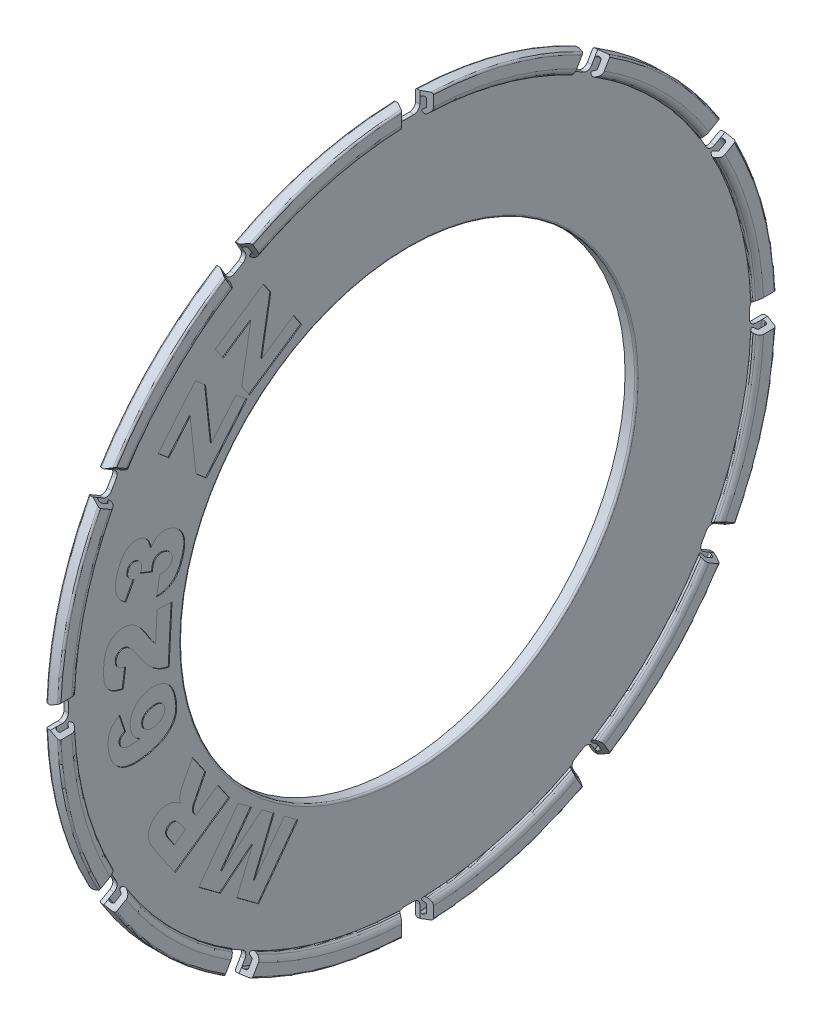
from build123d import *
from OCP.BRepFilletAPI import BRepFilletAPI_MakeFillet

# Parameters (mm, degrees)
FILLET1_R1         = 0.02
FILLET1_R2         = 0.08
SKETCH3_W          = 0.249361734
SKETCH3_H          = 0.345695775
CUT_EXTRUDE2_DEPTH = 6.799732894
CUT_EXTRUDE2_TAPER = -30
CUT_EXTRUDE3_REACH = 7.8
CIRPATTERN2_COUNT  = 12
CUT_EXTRUDE1_DEPTH = 0.01


with BuildPart() as part:
    # Sketch1 → Revolve1 (revolve)
    with BuildSketch(Plane.XY):
        Polygon((1.02, -2.65), (1.1, -2.65), (1.1, -4.1), (1.248703916, -4.1), (1.248703916, -3.92), (1.187420361, -3.868576991), (1.15528098, -3.906879213), (1.198703916, -3.943315383), (1.198703916, -4.05), (1.15, -4.05), (1.15, -2.6), (1.02, -2.6), align=None)
    revolve(axis=Axis((-6.429017492, 0, 0), (1, 0, 0)))

    # Fillet1: one fillet with a radius per group of edges: ONE call of the kernel's fillet builder (fillet() takes one radius for all edges)
    fillet1_edges_1 = [part.edges().sort_by_distance(p)[0] for p in [
        (1.187420361, 3.868576991, 0),
        (1.15528098, 3.906879213, 0),
        (1.15, 2.6, 0),
        (1.248703916, 4.1, 0),
        (1.1, 4.1, 0),
        (1.15, 4.05, 0),
        (1.198703916, 4.05, 0),
    ]]
    fillet1_edges_2 = [part.edges().sort_by_distance(p)[0] for p in [
        (1.248703916, 3.92, 0),
    ]]
    fillet1 = BRepFilletAPI_MakeFillet(part.part.solid().wrapped)
    for e in fillet1_edges_1:
        fillet1.Add(FILLET1_R1, e.wrapped)
    for e in fillet1_edges_2:
        fillet1.Add(FILLET1_R2, e.wrapped)
    add(Compound.cast(fillet1.Shape()), mode=Mode.REPLACE)

    # Sketch3 → Cut-Extrude2 (cut, through all)
    with BuildSketch(Plane(origin=(1.15, 0, 0), x_dir=(0, 0, -1), z_dir=(1, 0, 0))):
        with Locations((0, 3.957248854)):
            Rectangle(SKETCH3_W, SKETCH3_H)
    cut_extrude2 = extrude(amount=CUT_EXTRUDE2_DEPTH, taper=CUT_EXTRUDE2_TAPER, mode=Mode.SUBTRACT)

    # Cut-Extrude3: up to this face of the body (flat: up to its plane)
    cut_extrude3_end = Plane(part.part.faces().sort_by_distance((1.1, 3.964600173, 0))[0])
    # Sketch4 → Cut-Extrude3 (cut, up to the picked face)
    with BuildSketch(Plane(origin=(1.15, 0, 0), x_dir=(0, 0, -1), z_dir=(1, 0, 0)), mode=Mode.PRIVATE) as cut_extrude3_sk1:
        with BuildLine():
            Line((-0.124680867, 4.098103791), (-0.124680867, 3.96268108))
            ThreePointArc((-0.124680867, 3.96268108), (-0.104178342, 3.913183605), (-0.054680867, 3.89268108))
            Line((-0.054680867, 3.89268108), (0.054680867, 3.89268108))
            ThreePointArc((0.054680867, 3.89268108), (0.104178342, 3.913183605), (0.124680867, 3.96268108))
            Line((0.124680867, 3.96268108), (0.124680867, 4.098103791))
            ThreePointArc((0.124680867, 4.098103791), (0, 4.1), (-0.124680867, 4.098103791))
        make_face()
    cut_extrude3_tool1 = split(extrude(cut_extrude3_sk1.sketch, amount=-CUT_EXTRUDE3_REACH, mode=Mode.PRIVATE), bisect_by=cut_extrude3_end, keep=Keep.BOTH, mode=Mode.PRIVATE)
    cut_extrude3 = cut_extrude3_tool1.solids().sort_by(Axis((1.15, 3.999757, 0), (-1, 0, 0)))[0]
    add(cut_extrude3, mode=Mode.SUBTRACT)

    # CirPattern2: Cut-Extrude2, Cut-Extrude3 ×12 about axis
    cirpattern2_axis = Axis((0, 0, 0), (1, 0, 0))
    add([cut_extrude2.rotate(cirpattern2_axis, i * 360 / CIRPATTERN2_COUNT) for i in range(1, CIRPATTERN2_COUNT)], mode=Mode.SUBTRACT)
    add([cut_extrude3.rotate(cirpattern2_axis, i * 360 / CIRPATTERN2_COUNT) for i in range(1, CIRPATTERN2_COUNT)], mode=Mode.SUBTRACT)

    # Sketch2 → Cut-Extrude1 (cut)
    with BuildSketch(Plane(origin=(1.15, 0, 0), x_dir=(0, 0, -1), z_dir=(1, 0, 0))):
        Polygon((-2.212074833, 2.706157821), (-1.663424265, 3.076135499), (-1.57895795, 2.950729655), (-1.682904784, 2.346376977), (-1.31825381, 2.592318535), (-1.22739545, 2.457476814), (-1.822768826, 2.055995483), (-1.910583356, 2.186119266), (-1.807701862, 2.784079899), (-2.121825239, 2.572229249), align=None)
        Polygon((-2.866893351, 1.999189565), (-2.440756987, 2.505226496), (-2.325091403, 2.407823899), (-2.259649033, 1.798144516), (-1.976420542, 2.13448786), (-1.852080039, 2.029780068), (-2.314590185, 1.480672925), (-2.434669325, 1.581880311), (-2.499502929, 2.185015457), (-2.743465997, 1.89524273), align=None)
        with BuildLine():
            Line((-3.141397188, 0.890050122), (-3.234994996, 0.712290381))
            add(Edge.make_bspline(
                [(-3.234994996, 0.712290381), (-3.241652025, 0.716717018), (-3.254716815, 0.72540454), (-3.272940512, 0.739733467), (-3.289267173, 0.755137837), (-3.30379652, 0.771514362), (-3.316687436, 0.788790714), (-3.327785169, 0.807039293), (-3.337140333, 0.826251788), (-3.344830176, 0.846382003), (-3.35047259, 0.867753095), (-3.354119764, 0.890280058), (-3.355562981, 0.914076921), (-3.355057782, 0.939058583), (-3.352589821, 0.965358989), (-3.347977427, 0.992862404), (-3.341211907, 1.021605488), (-3.335394145, 1.040951868), (-3.332397593, 1.050916599)],
                knots=[0, 0, 0, 0, 0.996965878, 1.956601256, 2.88770829, 3.793173997, 4.684173077, 5.573012264, 6.45318163, 7.346402628, 8.25663212, 9.205419306, 10.188307953, 11.226283579, 12.319409183, 13.480414381, 14.702238262, 16, 16, 16, 16], degree=3))
            add(Edge.make_bspline(
                [(-3.332397593, 1.050916599), (-3.328675336, 1.062176722), (-3.321480778, 1.083940828), (-3.308895369, 1.114677512), (-3.295848569, 1.142701673), (-3.281461002, 1.167473761), (-3.266605518, 1.189563268), (-3.250552217, 1.208460808), (-3.233834011, 1.224700397), (-3.215990926, 1.237706128), (-3.197629089, 1.247986463), (-3.179187478, 1.256354815), (-3.160432751, 1.262318172), (-3.141460028, 1.266199054), (-3.122239136, 1.267729801), (-3.102852561, 1.266870021), (-3.083215593, 1.264078942), (-3.070339067, 1.26038676), (-3.063779493, 1.258505885)],
                knots=[0, 0, 0, 0, 1.486482005, 2.873143656, 4.16197067, 5.358788456, 6.461443456, 7.494932611, 8.462177862, 9.376883809, 10.254180828, 11.09697377, 11.911647764, 12.716227884, 13.52017922, 14.322241245, 15.145314161, 16, 16, 16, 16], degree=3))
            add(Edge.make_bspline(
                [(-3.063779493, 1.258505885), (-3.05627325, 1.255786904), (-3.041489309, 1.25043173), (-3.021159139, 1.238562115), (-3.002838189, 1.224060775), (-2.986931475, 1.206418047), (-2.973065732, 1.186063316), (-2.961590577, 1.162779945), (-2.952222287, 1.136674978), (-2.948014303, 1.118088437), (-2.945831035, 1.108445008)],
                knots=[0, 0, 0, 0, 0.951343852, 1.873721842, 2.795821485, 3.730286132, 4.69776014, 5.726874251, 6.820612936, 8, 8, 8, 8], degree=3))
            add(Edge.make_bspline(
                [(-2.945831035, 1.108445008), (-2.942066207, 1.114493909), (-2.934964492, 1.125904141), (-2.923542305, 1.141107076), (-2.912985264, 1.154144046), (-2.905277386, 1.161181261), (-2.901695483, 1.164451501)],
                knots=[0, 0, 0, 0, 1.193944278, 2.252174855, 3.187773934, 4, 4, 4, 4], degree=3))
            add(Edge.make_bspline(
                [(-2.901695483, 1.164451501), (-2.896016699, 1.168960545), (-2.884778888, 1.177883543), (-2.866219024, 1.188611368), (-2.846507989, 1.196530549), (-2.825832536, 1.202100475), (-2.8040212, 1.204879141), (-2.781249093, 1.204467835), (-2.757514572, 1.201111708), (-2.741798329, 1.196608404), (-2.733676003, 1.194281047)],
                knots=[0, 0, 0, 0, 0.972616807, 1.924722696, 2.865728001, 3.81734653, 4.792250057, 5.807182763, 6.866728094, 8, 8, 8, 8], degree=3))
            add(Edge.make_bspline(
                [(-2.733676003, 1.194281047), (-2.723405031, 1.19061102), (-2.702896462, 1.183282892), (-2.67424629, 1.167070072), (-2.647600099, 1.147128777), (-2.627326004, 1.127542297), (-2.612408075, 1.110339787), (-2.602292888, 1.09653717), (-2.593376442, 1.082090984), (-2.585363251, 1.067079644), (-2.578510688, 1.05141923), (-2.5728841, 1.035013445), (-2.568324391, 1.018036173), (-2.564945276, 1.00038764), (-2.562846997, 0.981975525), (-2.561862729, 0.962701691), (-2.562622397, 0.942521542), (-2.564420967, 0.921431427), (-2.567641424, 0.899431172), (-2.572266756, 0.876535574), (-2.578184953, 0.85276001), (-2.583083654, 0.83676179), (-2.585593616, 0.828564732)],
                knots=[0, 0, 0, 0, 1.468544657, 2.93231749, 4.418159492, 5.947000875, 6.72313198, 7.486618499, 8.251635851, 9.01057301, 9.779495404, 10.553996804, 11.347185151, 12.148152775, 12.974626404, 13.8443874, 14.747798274, 15.695402368, 16.697679072, 17.744132734, 18.844154151, 20, 20, 20, 20], degree=3))
            add(Edge.make_bspline(
                [(-2.585593616, 0.828564732), (-2.588176667, 0.820631812), (-2.593204973, 0.80518916), (-2.601455124, 0.782965659), (-2.609890597, 0.762261113), (-2.618852313, 0.743130154), (-2.627789962, 0.725318468), (-2.637477837, 0.709217365), (-2.647160583, 0.694500321), (-2.660472911, 0.677170892), (-2.678401335, 0.658069034), (-2.701752935, 0.638203945), (-2.727186872, 0.621922415), (-2.75449044, 0.608912505), (-2.783826529, 0.59908208), (-2.815273453, 0.592770731), (-2.848777556, 0.588711328), (-2.871853383, 0.588811461), (-2.883736879, 0.588863027)],
                knots=[0, 0, 0, 0, 0.957077744, 1.863099244, 2.719135602, 3.521173556, 4.286468441, 5.004158756, 5.675688924, 6.306645927, 7.509093788, 8.673877084, 9.815319901, 10.963391327, 12.135813007, 13.354935907, 14.637855525, 16, 16, 16, 16], degree=3))
            Line((-2.883736879, 0.588863027), (-2.846906522, 0.796604505))
            add(Edge.make_bspline(
                [(-2.846906522, 0.796604505), (-2.84173485, 0.796116766), (-2.831758425, 0.795175892), (-2.817291302, 0.794318742), (-2.803867737, 0.794469213), (-2.791479013, 0.795426964), (-2.780043887, 0.79680153), (-2.769659634, 0.799272541), (-2.760296903, 0.802418464), (-2.749308866, 0.807738941), (-2.737185159, 0.816209466), (-2.724837753, 0.828957383), (-2.715099371, 0.844505375), (-2.71079128, 0.856169694), (-2.708564395, 0.862199066)],
                knots=[0, 0, 0, 0, 1.106073005, 2.133672459, 3.084299769, 3.961649642, 4.778960599, 5.53354789, 6.230416036, 6.877808649, 8.127330516, 9.357275926, 10.633956453, 12, 12, 12, 12], degree=3))
            add(Edge.make_bspline(
                [(-2.708564395, 0.862199066), (-2.706839977, 0.868747377), (-2.703468701, 0.881549469), (-2.70363803, 0.901346703), (-2.707818281, 0.920554317), (-2.716324791, 0.938806489), (-2.72853607, 0.955642955), (-2.74453588, 0.970206792), (-2.764255971, 0.981837995), (-2.778977061, 0.987232435), (-2.786638665, 0.990039975)],
                knots=[0, 0, 0, 0, 0.965377401, 1.887334252, 2.801512917, 3.75979478, 4.747193907, 5.759497664, 6.833928598, 8, 8, 8, 8], degree=3))
            add(Edge.make_bspline(
                [(-2.786638665, 0.990039975), (-2.790731478, 0.99126852), (-2.798646977, 0.993644524), (-2.81050287, 0.996108477), (-2.821908646, 0.997515346), (-2.832910506, 0.997786997), (-2.843467131, 0.997249201), (-2.853574645, 0.995564832), (-2.863234135, 0.992825446), (-2.875300833, 0.98775514), (-2.889215679, 0.97924007), (-2.903214877, 0.965236291), (-2.914556792, 0.947872788), (-2.91941207, 0.934562951), (-2.92193696, 0.927641437)],
                knots=[0, 0, 0, 0, 0.910977311, 1.761829841, 2.57907118, 3.358334845, 4.106094558, 4.829993581, 5.53886079, 6.242091453, 7.617117862, 8.986514487, 10.432897026, 12, 12, 12, 12], degree=3))
            add(Edge.make_bspline(
                [(-2.92193696, 0.927641437), (-2.923067095, 0.923293036), (-2.925529919, 0.913816872), (-2.928047247, 0.897987823), (-2.929577634, 0.879472098), (-2.930153434, 0.866209351), (-2.930459688, 0.859155235)],
                knots=[0, 0, 0, 0, 0.778957448, 1.697527352, 2.775373591, 4, 4, 4, 4], degree=3))
            Line((-2.930459688, 0.859155235), (-3.069867155, 0.914857346))
            add(Edge.make_bspline(
                [(-3.069867155, 0.914857346), (-3.067588218, 0.919585481), (-3.063613972, 0.927830894), (-3.060529501, 0.936446116), (-3.059213746, 0.940121144)],
                knots=[0, 0, 0, 0, 1.146852366, 2, 2, 2, 2], degree=3))
            add(Edge.make_bspline(
                [(-3.059213746, 0.940121144), (-3.057488932, 0.946467761), (-3.054121916, 0.958857017), (-3.053433036, 0.977878384), (-3.056333937, 0.99625753), (-3.062971575, 1.013482869), (-3.072239925, 1.029050803), (-3.08396119, 1.042183531), (-3.098169841, 1.052296388), (-3.1089674, 1.056324962), (-3.114459282, 1.058373985)],
                knots=[0, 0, 0, 0, 1.08461134, 2.117274327, 3.119891392, 4.141971817, 5.150467332, 6.100726669, 7.033986697, 8, 8, 8, 8], degree=3))
            add(Edge.make_bspline(
                [(-3.114459282, 1.058373985), (-3.119745281, 1.059848661), (-3.12988587, 1.06267766), (-3.145293758, 1.063477981), (-3.15978419, 1.061121702), (-3.173328131, 1.056004686), (-3.185295152, 1.047702639), (-3.195766217, 1.037026145), (-3.204053729, 1.023444716), (-3.207782149, 1.013201222), (-3.209731197, 1.007846388)],
                knots=[0, 0, 0, 0, 1.078489428, 2.068959391, 3.010225977, 3.952870467, 4.89514418, 5.856145084, 6.879289992, 8, 8, 8, 8], degree=3))
            add(Edge.make_bspline(
                [(-3.209731197, 1.007846388), (-3.211275304, 1.002153641), (-3.214259155, 0.991152905), (-3.214935751, 0.974388971), (-3.212741472, 0.958363596), (-3.206938511, 0.943012855), (-3.197096815, 0.928370056), (-3.182518323, 0.914860399), (-3.163823026, 0.90155429), (-3.149224101, 0.894065228), (-3.141397188, 0.890050122)],
                knots=[0, 0, 0, 0, 0.931616347, 1.800267452, 2.6365463, 3.478172771, 4.376201162, 5.404643436, 6.608553058, 8, 8, 8, 8], degree=3))
        make_face()
        with BuildLine():
            Line((-2.708015014, 0.451318248), (-2.74088839, -0.176471931))
            add(Edge.make_bspline(
                [(-2.74088839, -0.176471931), (-2.748572037, -0.175055613), (-2.763846211, -0.172240142), (-2.786375266, -0.166130244), (-2.808523188, -0.15893608), (-2.830235826, -0.150141865), (-2.851536635, -0.140191181), (-2.872283803, -0.128566516), (-2.892882866, -0.116095913), (-2.913092173, -0.10166559), (-2.933515243, -0.085095951), (-2.954474013, -0.065749172), (-2.976067704, -0.043250745), (-2.998412162, -0.017730441), (-3.021653279, 0.010661705), (-3.045565624, 0.042201611), (-3.070380175, 0.076643351), (-3.086643344, 0.101021529), (-3.095038147, 0.113605179)],
                knots=[0, 0, 0, 0, 0.793429032, 1.577242224, 2.369314293, 3.15790796, 3.95559384, 4.756022087, 5.572759965, 6.400737883, 7.276468852, 8.243030276, 9.296379999, 10.442997531, 11.68822691, 13.023092273, 14.463364906, 16, 16, 16, 16], degree=3))
            add(Edge.make_bspline(
                [(-3.095038147, 0.113605179), (-3.100138657, 0.121230345), (-3.109918298, 0.135850721), (-3.124342923, 0.156616675), (-3.138057591, 0.175103412), (-3.150645785, 0.191620908), (-3.162362744, 0.205941848), (-3.173127556, 0.218225002), (-3.183131792, 0.228248471), (-3.194859699, 0.238647252), (-3.208873113, 0.248750628), (-3.225586738, 0.257920208), (-3.242111011, 0.264091761), (-3.253272602, 0.265345549), (-3.258644072, 0.265948929)],
                knots=[0, 0, 0, 0, 1.430961346, 2.74370368, 3.943369243, 5.021209643, 5.98274246, 6.829149717, 7.567744642, 8.190069628, 9.272779028, 10.253558271, 11.159531995, 12, 12, 12, 12], degree=3))
            add(Edge.make_bspline(
                [(-3.258644072, 0.265948929), (-3.264197304, 0.265929377), (-3.275157005, 0.265890789), (-3.291099353, 0.261751401), (-3.305941623, 0.254424623), (-3.319135992, 0.243863735), (-3.330639044, 0.231090828), (-3.33910425, 0.215945862), (-3.344759222, 0.199047624), (-3.345980891, 0.18705654), (-3.346610793, 0.180873848)],
                knots=[0, 0, 0, 0, 0.975318568, 1.924860908, 2.872255198, 3.871807218, 4.885053729, 5.881764118, 6.907821917, 8, 8, 8, 8], degree=3))
            add(Edge.make_bspline(
                [(-3.346610793, 0.180873848), (-3.346651482, 0.174464181), (-3.346730155, 0.162070797), (-3.34282415, 0.144119191), (-3.335551895, 0.127959501), (-3.326976319, 0.115863971), (-3.318215593, 0.107344633), (-3.310348999, 0.101321201), (-3.301169733, 0.095810297), (-3.290912101, 0.090672455), (-3.279341455, 0.086084569), (-3.266537306, 0.082085076), (-3.252568629, 0.078173887), (-3.242730943, 0.076248805), (-3.237641637, 0.075252907)],
                knots=[0, 0, 0, 0, 1.361875955, 2.633249472, 3.87602828, 5.114291299, 5.763646398, 6.472382254, 7.219047427, 8.040367039, 8.913013902, 9.866199743, 10.896126464, 12, 12, 12, 12], degree=3))
            Line((-3.237641637, 0.075252907), (-3.265644884, -0.13340172))
            add(Edge.make_bspline(
                [(-3.265644884, -0.13340172), (-3.272761562, -0.131943187), (-3.286653459, -0.129096103), (-3.306689343, -0.123883056), (-3.325544571, -0.118258288), (-3.343151843, -0.112089854), (-3.35950984, -0.1052148), (-3.374629411, -0.097781806), (-3.388474798, -0.089690244), (-3.4053537, -0.078422311), (-3.424141717, -0.062030692), (-3.443778963, -0.039309812), (-3.459799071, -0.01305803), (-3.470985488, 0.010922544), (-3.477903156, 0.0320308), (-3.482573966, 0.04942467), (-3.485872104, 0.068288875), (-3.488755355, 0.088473711), (-3.490253942, 0.110085069), (-3.49121661, 0.133074658), (-3.491207599, 0.15744693), (-3.490494069, 0.174128546), (-3.490127433, 0.182700147)],
                knots=[0, 0, 0, 0, 0.997034666, 1.946231286, 2.840666683, 3.697414948, 4.505731738, 5.274948675, 6.008278083, 6.705507205, 8.058273482, 9.416316791, 10.811400837, 12.266591674, 13.037320093, 13.858197364, 14.736410977, 15.664112006, 16.655904539, 17.708236726, 18.822411473, 20, 20, 20, 20], degree=3))
            add(Edge.make_bspline(
                [(-3.490127433, 0.182700147), (-3.489587271, 0.191634285), (-3.488536162, 0.209019392), (-3.485866374, 0.23428408), (-3.482791294, 0.258015602), (-3.478771372, 0.280134581), (-3.474308868, 0.300687916), (-3.468982828, 0.319649175), (-3.462891862, 0.337017432), (-3.456178095, 0.353001779), (-3.44867817, 0.367772681), (-3.440228115, 0.381488589), (-3.431139547, 0.394449935), (-3.421216585, 0.406506289), (-3.410539876, 0.417656813), (-3.39903043, 0.427921986), (-3.386729999, 0.43735181), (-3.373620496, 0.445837936), (-3.360033876, 0.453451962), (-3.345954173, 0.459833456), (-3.33157377, 0.465207971), (-3.316877888, 0.469472842), (-3.301804303, 0.472509664), (-3.286450319, 0.474517147), (-3.270721879, 0.475274092), (-3.260165565, 0.474929576), (-3.254839283, 0.474755748)],
                knots=[0, 0, 0, 0, 1.517404861, 2.952746514, 4.306707147, 5.573838247, 6.763387418, 7.871665646, 8.910864369, 9.882203375, 10.809307837, 11.716567676, 12.611511199, 13.49148966, 14.36144762, 15.226501486, 16.103911768, 16.986660499, 17.872254385, 18.74216982, 19.604954155, 20.473379898, 21.333716735, 22.209650071, 23.096663112, 24, 24, 24, 24], degree=3))
            add(Edge.make_bspline(
                [(-3.254839283, 0.474755748), (-3.249148243, 0.474333172), (-3.237765937, 0.473488004), (-3.22092676, 0.470706339), (-3.204284641, 0.466720062), (-3.187952833, 0.461419874), (-3.171859955, 0.45478861), (-3.156034606, 0.447035674), (-3.140444687, 0.43803086), (-3.125067638, 0.427572143), (-3.109728457, 0.415341768), (-3.094009646, 0.401385698), (-3.078267179, 0.385117547), (-3.062061896, 0.367028492), (-3.045840551, 0.346621978), (-3.029070468, 0.324326427), (-3.012238998, 0.299772165), (-3.001191797, 0.282567432), (-2.995504868, 0.273710699)],
                knots=[0, 0, 0, 0, 0.800215034, 1.600461711, 2.390998423, 3.198929055, 4.006389423, 4.830702468, 5.669268767, 6.529861257, 7.436785155, 8.419605114, 9.476394529, 10.610505815, 11.825276582, 13.131860768, 14.523525948, 16, 16, 16, 16], degree=3))
            add(Edge.make_bspline(
                [(-2.995504868, 0.273710699), (-2.992266052, 0.268480482), (-2.986063045, 0.258463527), (-2.977022282, 0.244145385), (-2.96891367, 0.231088582), (-2.961358433, 0.219482801), (-2.954718393, 0.209147871), (-2.948783889, 0.200166918), (-2.943618491, 0.192550142), (-2.937597291, 0.183989034), (-2.929755044, 0.173856028), (-2.919602367, 0.161275923), (-2.90813421, 0.147721291), (-2.900040965, 0.138402899), (-2.895819397, 0.133542274)],
                knots=[0, 0, 0, 0, 1.285272736, 2.461565029, 3.537867242, 4.496295874, 5.354745273, 6.104353983, 6.745217981, 7.277492065, 8.290787016, 9.421352561, 10.654935392, 12, 12, 12, 12], degree=3))
            Line((-2.895819397, 0.133542274), (-2.878621751, 0.46029755))
            Line((-2.878621751, 0.46029755), (-2.708015014, 0.451318248))
        make_face()
        with BuildLine():
            Line((-3.305913474, -0.369455799), (-3.238796997, -0.568522357))
            add(Edge.make_bspline(
                [(-3.238796997, -0.568522357), (-3.245158881, -0.571267245), (-3.257085118, -0.576412919), (-3.272784073, -0.585815616), (-3.285149072, -0.596044088), (-3.294129854, -0.607200114), (-3.299873898, -0.619131335), (-3.303149461, -0.631577539), (-3.303961762, -0.644734426), (-3.302535772, -0.653509673), (-3.301804302, -0.658010994)],
                knots=[0, 0, 0, 0, 1.376229227, 2.579932909, 3.62451481, 4.550563211, 5.402963822, 6.237033689, 7.095674723, 8, 8, 8, 8], degree=3))
            add(Edge.make_bspline(
                [(-3.301804302, -0.658010994), (-3.300861106, -0.662055866), (-3.299013407, -0.669979673), (-3.294197879, -0.681073089), (-3.287848735, -0.691059872), (-3.280206866, -0.700117759), (-3.271117117, -0.708099367), (-3.260583748, -0.714974865), (-3.248663666, -0.720994043), (-3.239956949, -0.723917925), (-3.235448782, -0.725431854)],
                knots=[0, 0, 0, 0, 0.997858564, 1.954780912, 2.892909725, 3.836976372, 4.797008143, 5.792399625, 6.856947905, 8, 8, 8, 8], degree=3))
            add(Edge.make_bspline(
                [(-3.235448782, -0.725431854), (-3.231660809, -0.726430469), (-3.223364981, -0.728617481), (-3.209356978, -0.730188049), (-3.192957606, -0.731275858), (-3.174004935, -0.731345294), (-3.152540391, -0.730497149), (-3.128531202, -0.72899482), (-3.102041606, -0.726535187), (-3.083607172, -0.724311208), (-3.073973539, -0.723148981)],
                knots=[0, 0, 0, 0, 0.578532959, 1.267012559, 2.078796009, 3.008922317, 4.067196305, 5.25469, 6.565330996, 8, 8, 8, 8], degree=3))
            add(Edge.make_bspline(
                [(-3.073973539, -0.723148981), (-3.081166869, -0.718301075), (-3.095145518, -0.70888024), (-3.114074814, -0.693057801), (-3.130791115, -0.676658582), (-3.145190242, -0.659211429), (-3.157500677, -0.64041503), (-3.167208463, -0.619607941), (-3.175729431, -0.597152384), (-3.179286585, -0.581161614), (-3.181116396, -0.572935913)],
                knots=[0, 0, 0, 0, 1.094092579, 2.126127191, 3.108513383, 4.045476207, 4.976008096, 5.935278565, 6.937900982, 8, 8, 8, 8], degree=3))
            add(Edge.make_bspline(
                [(-3.181116396, -0.572935913), (-3.18262125, -0.564791868), (-3.18557718, -0.548794818), (-3.186768865, -0.524697552), (-3.185985057, -0.501138799), (-3.18252543, -0.478056125), (-3.177002918, -0.455389269), (-3.168578553, -0.433395427), (-3.158110148, -0.411820902), (-3.14512331, -0.391117323), (-3.130422608, -0.371411625), (-3.113693748, -0.353496578), (-3.095350834, -0.337489166), (-3.075487364, -0.323208479), (-3.053926355, -0.311030064), (-3.030759591, -0.300828071), (-3.006019058, -0.292358953), (-2.98873755, -0.288386346), (-2.979919156, -0.286359208)],
                knots=[0, 0, 0, 0, 1.015217046, 1.994153795, 2.953538227, 3.903444368, 4.853105709, 5.810468424, 6.787661882, 7.791304586, 8.804745155, 9.800168768, 10.792765989, 11.787780759, 12.796948867, 13.825306894, 14.890299314, 16, 16, 16, 16], degree=3))
            add(Edge.make_bspline(
                [(-2.979919156, -0.286359208), (-2.973895744, -0.285205508), (-2.961905284, -0.282908903), (-2.943836097, -0.281055777), (-2.925955023, -0.28005676), (-2.90825332, -0.28036094), (-2.890726623, -0.281942172), (-2.87336561, -0.284443963), (-2.856220703, -0.288378087), (-2.839238376, -0.293123221), (-2.822789991, -0.299213515), (-2.806961422, -0.306249301), (-2.791892595, -0.314313801), (-2.777544317, -0.323407089), (-2.764141221, -0.333748572), (-2.75127717, -0.344819769), (-2.73924124, -0.357054923), (-2.727949923, -0.370331293), (-2.717451299, -0.384690674), (-2.707594152, -0.400147895), (-2.698765706, -0.416935897), (-2.690267754, -0.434652693), (-2.683040516, -0.453760676), (-2.676360756, -0.473909679), (-2.670377509, -0.495284795), (-2.667143765, -0.510012608), (-2.665491396, -0.517538185)],
                knots=[0, 0, 0, 0, 1.000929695, 1.992493116, 2.962899351, 3.923891704, 4.880052671, 5.834777421, 6.78532487, 7.750164913, 8.711906634, 9.646292579, 10.576446766, 11.50016126, 12.416305573, 13.338124046, 14.269420861, 15.215482523, 16.181353131, 17.171774177, 18.205713531, 19.276585623, 20.377969038, 21.538354381, 22.742155216, 24, 24, 24, 24], degree=3))
            add(Edge.make_bspline(
                [(-2.665491396, -0.517538185), (-2.663781419, -0.526553985), (-2.660440072, -0.544171136), (-2.656996463, -0.570232613), (-2.654707569, -0.59516111), (-2.65431954, -0.619007379), (-2.655181539, -0.641675317), (-2.657408891, -0.66325413), (-2.661201774, -0.683721199), (-2.66654018, -0.703174617), (-2.673458012, -0.721744652), (-2.681907276, -0.739633771), (-2.691778694, -0.757052681), (-2.703452192, -0.773860305), (-2.716712298, -0.790061687), (-2.731360569, -0.805872325), (-2.74777625, -0.820928205), (-2.765699421, -0.835554674), (-2.785417917, -0.849487828), (-2.807046331, -0.862394616), (-2.830691922, -0.874277843), (-2.856205813, -0.885335655), (-2.883650775, -0.89550739), (-2.913002479, -0.904809037), (-2.944293482, -0.913159626), (-2.965947183, -0.917841371), (-2.977027516, -0.920237049)],
                knots=[0, 0, 0, 0, 1.129677814, 2.207425309, 3.235555562, 4.210169223, 5.141632426, 6.027340175, 6.878796051, 7.701658798, 8.508045382, 9.315592375, 10.135295873, 10.970442589, 11.831852822, 12.7113495, 13.621906363, 14.572093796, 15.558189464, 16.59193987, 17.670230266, 18.81440745, 20.014116808, 21.272492673, 22.604317472, 24, 24, 24, 24], degree=3))
            add(Edge.make_bspline(
                [(-2.977027516, -0.920237049), (-2.993225349, -0.923353002), (-3.024518553, -0.92937283), (-3.070463056, -0.934458095), (-3.113521916, -0.936566175), (-3.153864771, -0.935562202), (-3.191466931, -0.930817803), (-3.226363041, -0.923042323), (-3.258453827, -0.911797815), (-3.28763365, -0.897028833), (-3.314056059, -0.879265382), (-3.33798879, -0.85887286), (-3.359422064, -0.835885591), (-3.378415274, -0.810265617), (-3.394893139, -0.781986652), (-3.408671897, -0.751017833), (-3.420281649, -0.717544214), (-3.425564553, -0.693991301), (-3.428275487, -0.681905068)],
                knots=[0, 0, 0, 0, 1.358393524, 2.624331739, 3.804117078, 4.907931701, 5.944145187, 6.921470006, 7.848055704, 8.737704696, 9.608192535, 10.464928045, 11.322427703, 12.191710852, 13.086966777, 14.012873644, 14.980301475, 16, 16, 16, 16], degree=3))
            add(Edge.make_bspline(
                [(-3.428275487, -0.681905068), (-3.429697015, -0.674761595), (-3.432471369, -0.660819887), (-3.435657583, -0.640306478), (-3.437915952, -0.620806096), (-3.43952018, -0.602335538), (-3.440134415, -0.584862105), (-3.439877941, -0.568397049), (-3.438639727, -0.553004545), (-3.436086287, -0.534029127), (-3.430598637, -0.511687136), (-3.421595936, -0.4862622), (-3.409405393, -0.462640803), (-3.394492262, -0.440670621), (-3.376735084, -0.420239964), (-3.355752943, -0.401759484), (-3.332258618, -0.384288873), (-3.314860229, -0.374493079), (-3.305913474, -0.369455799)],
                knots=[0, 0, 0, 0, 0.954893233, 1.863637011, 2.720847669, 3.528416024, 4.293794443, 5.012273361, 5.686173113, 6.317359579, 7.520884693, 8.694934894, 9.846172531, 10.995506325, 12.169349251, 13.38458066, 14.655075761, 16, 16, 16, 16], degree=3))
        make_face()
        with BuildLine():
            add(Edge.make_bspline(
                [(-2.899105438, -0.68007877), (-2.894268508, -0.678979181), (-2.884814561, -0.676829997), (-2.871280405, -0.67255974), (-2.858738637, -0.667567996), (-2.847252797, -0.661724409), (-2.836653653, -0.655243963), (-2.827260848, -0.647724951), (-2.818715781, -0.639594715), (-2.811358824, -0.630640025), (-2.804976692, -0.621271425), (-2.799730336, -0.61157549), (-2.795651882, -0.60166952), (-2.792478206, -0.591617094), (-2.790874945, -0.581258323), (-2.790278607, -0.570763137), (-2.790650496, -0.560031019), (-2.791925723, -0.552937525), (-2.792571347, -0.549346221)],
                knots=[0, 0, 0, 0, 1.259530025, 2.461795273, 3.600798142, 4.684213274, 5.731864284, 6.750179252, 7.734414963, 8.722691344, 9.687674891, 10.610167385, 11.517139442, 12.405801891, 13.280717912, 14.171340133, 15.074183522, 16, 16, 16, 16], degree=3))
            add(Edge.make_bspline(
                [(-2.792571347, -0.549346221), (-2.794269161, -0.542899664), (-2.797575238, -0.530346568), (-2.807285412, -0.513379371), (-2.820469976, -0.498964866), (-2.83424752, -0.489477614), (-2.846627188, -0.483149417), (-2.857014229, -0.479640066), (-2.868026386, -0.476753747), (-2.879892605, -0.475392501), (-2.892509591, -0.474675609), (-2.905884921, -0.475449367), (-2.920028348, -0.476903623), (-2.929605085, -0.478707852), (-2.934566071, -0.479642487)],
                knots=[0, 0, 0, 0, 1.343558235, 2.616251763, 3.909012857, 5.264041033, 5.975290217, 6.715196572, 7.47670033, 8.273405669, 9.126028439, 10.029898385, 10.979438714, 12, 12, 12, 12], degree=3))
            add(Edge.make_bspline(
                [(-2.934566071, -0.479642487), (-2.939606807, -0.48073494), (-2.949369562, -0.482850772), (-2.963351295, -0.487170893), (-2.976165989, -0.492206477), (-2.988086264, -0.497548252), (-2.998586266, -0.504123303), (-3.008275231, -0.510994785), (-3.016660006, -0.518861743), (-3.026281676, -0.529832896), (-3.035600285, -0.544705425), (-3.042777143, -0.563846493), (-3.045164103, -0.58407545), (-3.043280111, -0.597453398), (-3.042317695, -0.604287374)],
                knots=[0, 0, 0, 0, 1.003348138, 1.943256238, 2.843388854, 3.682501785, 4.479930272, 5.250003065, 5.990462638, 6.711112567, 8.086111475, 9.3790688, 10.661126397, 12, 12, 12, 12], degree=3))
            add(Edge.make_bspline(
                [(-3.042317695, -0.604287374), (-3.040536397, -0.61114658), (-3.037070649, -0.624492064), (-3.026839927, -0.642504133), (-3.013268945, -0.658018916), (-2.998998587, -0.668323454), (-2.986172997, -0.674995326), (-2.975632527, -0.678920909), (-2.964463612, -0.681819137), (-2.952635578, -0.683640407), (-2.940154968, -0.684370902), (-2.927027069, -0.684033508), (-2.913238696, -0.682664498), (-2.903914516, -0.680958607), (-2.899105438, -0.68007877)],
                knots=[0, 0, 0, 0, 1.395403329, 2.714939882, 4.050491595, 5.442216064, 6.164169728, 6.903459352, 7.659754088, 8.441087839, 9.264760513, 10.127244031, 11.034099634, 12, 12, 12, 12], degree=3))
        make_face(mode=Mode.SUBTRACT)
        with BuildLine():
            Line((-2.050248007, -1.816531337), (-2.670732991, -2.246168107))
            Line((-2.670732991, -2.246168107), (-2.892019517, -1.926565834))
            add(Edge.make_bspline(
                [(-2.892019517, -1.926565834), (-2.896987225, -1.919342301), (-2.906596392, -1.905369631), (-2.919813747, -1.884532432), (-2.931948373, -1.864862279), (-2.942351701, -1.845916374), (-2.951744257, -1.828205315), (-2.959538086, -1.811379257), (-2.965977824, -1.795543985), (-2.972671711, -1.775895453), (-2.978038819, -1.751716691), (-2.979450796, -1.722585111), (-2.975804842, -1.693550606), (-2.968923415, -1.669782268), (-2.961195869, -1.651150876), (-2.953919406, -1.637591301), (-2.945777926, -1.624372689), (-2.936046258, -1.611958344), (-2.925397212, -1.59983387), (-2.913452797, -1.588342672), (-2.900543142, -1.577060815), (-2.891068213, -1.57035631), (-2.886236237, -1.566937181)],
                knots=[0, 0, 0, 0, 1.273265003, 2.462909801, 3.583842418, 4.629491187, 5.601763304, 6.495196087, 7.321669269, 8.083639893, 9.50870878, 10.902963391, 12.298599811, 13.739921521, 14.483024362, 15.224664401, 15.972937096, 16.73490772, 17.512676547, 18.315150214, 19.140768888, 20, 20, 20, 20], degree=3))
            add(Edge.make_bspline(
                [(-2.886236237, -1.566937181), (-2.877731611, -1.561455938), (-2.861188457, -1.550793851), (-2.835048332, -1.538626515), (-2.808625565, -1.53075108), (-2.782180182, -1.526752837), (-2.755826849, -1.526550648), (-2.729802743, -1.529411425), (-2.704031062, -1.535648434), (-2.687601809, -1.542368665), (-2.679255718, -1.545782555)],
                knots=[0, 0, 0, 0, 1.112083918, 2.163219785, 3.158980477, 4.135207895, 5.095078329, 6.049629888, 7.009208306, 8, 8, 8, 8], degree=3))
            add(Edge.make_bspline(
                [(-2.679255718, -1.545782555), (-2.673708009, -1.548450434), (-2.661939094, -1.554110076), (-2.644749776, -1.56570318), (-2.626322738, -1.579519617), (-2.614337003, -1.590321684), (-2.608030069, -1.596005769)],
                knots=[0, 0, 0, 0, 0.843158393, 1.788676853, 2.836394241, 4, 4, 4, 4], degree=3))
            add(Edge.make_bspline(
                [(-2.608030069, -1.596005769), (-2.609872206, -1.589376643), (-2.613326455, -1.576946162), (-2.617171451, -1.559334858), (-2.619512791, -1.544020526), (-2.619779183, -1.53457753), (-2.61990101, -1.530259016)],
                knots=[0, 0, 0, 0, 1.231764342, 2.309719633, 3.226993273, 4, 4, 4, 4], degree=3))
            add(Edge.make_bspline(
                [(-2.61990101, -1.530259016), (-2.619718191, -1.527155132), (-2.61929518, -1.519973322), (-2.616649115, -1.508050681), (-2.613445424, -1.493319534), (-2.608683385, -1.47691537), (-2.603509303, -1.460422342), (-2.598385214, -1.44568407), (-2.593614359, -1.433540849), (-2.590113969, -1.426546505), (-2.588549549, -1.423420542)],
                knots=[0, 0, 0, 0, 0.666210599, 1.541487568, 2.613533809, 3.902381679, 5.203671867, 6.322497485, 7.250278455, 8, 8, 8, 8], degree=3))
            Line((-2.588549549, -1.423420542), (-2.472883965, -1.206243188))
            Line((-2.472883965, -1.206243188), (-2.322823088, -1.422963967))
            Line((-2.322823088, -1.422963967), (-2.441532504, -1.656730201))
            add(Edge.make_bspline(
                [(-2.441532504, -1.656730201), (-2.445055678, -1.663677248), (-2.451568475, -1.676519275), (-2.458772056, -1.694933914), (-2.463907665, -1.710496083), (-2.464854503, -1.720166857), (-2.465274387, -1.724455444)],
                knots=[0, 0, 0, 0, 1.292876629, 2.389958969, 3.286013647, 4, 4, 4, 4], degree=3))
            add(Edge.make_bspline(
                [(-2.465274387, -1.724455444), (-2.465089001, -1.729498647), (-2.464721467, -1.739496989), (-2.461158777, -1.754163866), (-2.455595845, -1.76834971), (-2.450103568, -1.776989619), (-2.447315783, -1.781375087)],
                knots=[0, 0, 0, 0, 0.997112696, 1.976813703, 2.973065575, 4, 4, 4, 4], degree=3))
            Line((-2.447315783, -1.781375087), (-2.435444841, -1.798420542))
            Line((-2.435444841, -1.798420542), (-2.183567812, -1.624009016))
            Line((-2.183567812, -1.624009016), (-2.050248007, -1.816531337))
        make_face()
        with BuildLine():
            Line((-2.552632341, -1.879538642), (-2.608791026, -1.798572733))
            add(Edge.make_bspline(
                [(-2.608791026, -1.798572733), (-2.610779586, -1.795951343), (-2.615525468, -1.789695153), (-2.625020091, -1.779795213), (-2.637496973, -1.76746023), (-2.647059594, -1.758664785), (-2.652317812, -1.753828415)],
                knots=[0, 0, 0, 0, 0.631189412, 1.506391623, 2.628834231, 4, 4, 4, 4], degree=3))
            add(Edge.make_bspline(
                [(-2.652317812, -1.753828415), (-2.65522175, -1.751271162), (-2.660910732, -1.746261354), (-2.670989978, -1.740853755), (-2.681863761, -1.737309677), (-2.693414777, -1.735899222), (-2.705140925, -1.736118799), (-2.716593077, -1.738470793), (-2.72767649, -1.74256171), (-2.734315118, -1.74679935), (-2.737697276, -1.748958285)],
                knots=[0, 0, 0, 0, 0.999700181, 1.958470803, 2.939418126, 3.946950437, 4.959357726, 5.964658511, 6.963061783, 8, 8, 8, 8], degree=3))
            add(Edge.make_bspline(
                [(-2.737697276, -1.748958285), (-2.742328951, -1.752425598), (-2.751159537, -1.759036253), (-2.761329818, -1.771567125), (-2.768073752, -1.78525007), (-2.770837065, -1.797618955), (-2.77112368, -1.80810669), (-2.769695352, -1.81671409), (-2.767479083, -1.826086874), (-2.763678841, -1.836039865), (-2.758982785, -1.846826425), (-2.752800875, -1.858115089), (-2.745661233, -1.870276059), (-2.740133819, -1.878354248), (-2.737240702, -1.882582473)],
                knots=[0, 0, 0, 0, 1.353485242, 2.580507166, 3.746417295, 4.904584073, 5.523699303, 6.197083379, 6.944850549, 7.780837285, 8.692163186, 9.703991385, 10.798240509, 12, 12, 12, 12], degree=3))
            Line((-2.737240702, -1.882582473), (-2.678799143, -1.966896597))
            Line((-2.678799143, -1.966896597), (-2.552632341, -1.879538642))
        make_face(mode=Mode.SUBTRACT)
        Polygon((-1.718982376, -3.031663129), (-1.965684892, -2.84918545), (-1.787620768, -2.409656229), (-2.155619957, -2.70856045), (-2.401257132, -2.526843729), (-1.952292035, -1.920208177), (-1.799339518, -2.033286505), (-2.141770525, -2.495948843), (-1.680477911, -2.121253226), (-1.541831402, -2.223982528), (-1.766009567, -2.774155012), (-1.423578561, -2.311492674), (-1.270017278, -2.425027577), align=None)
    extrude(amount=-CUT_EXTRUDE1_DEPTH, mode=Mode.SUBTRACT)


solid = part.part
